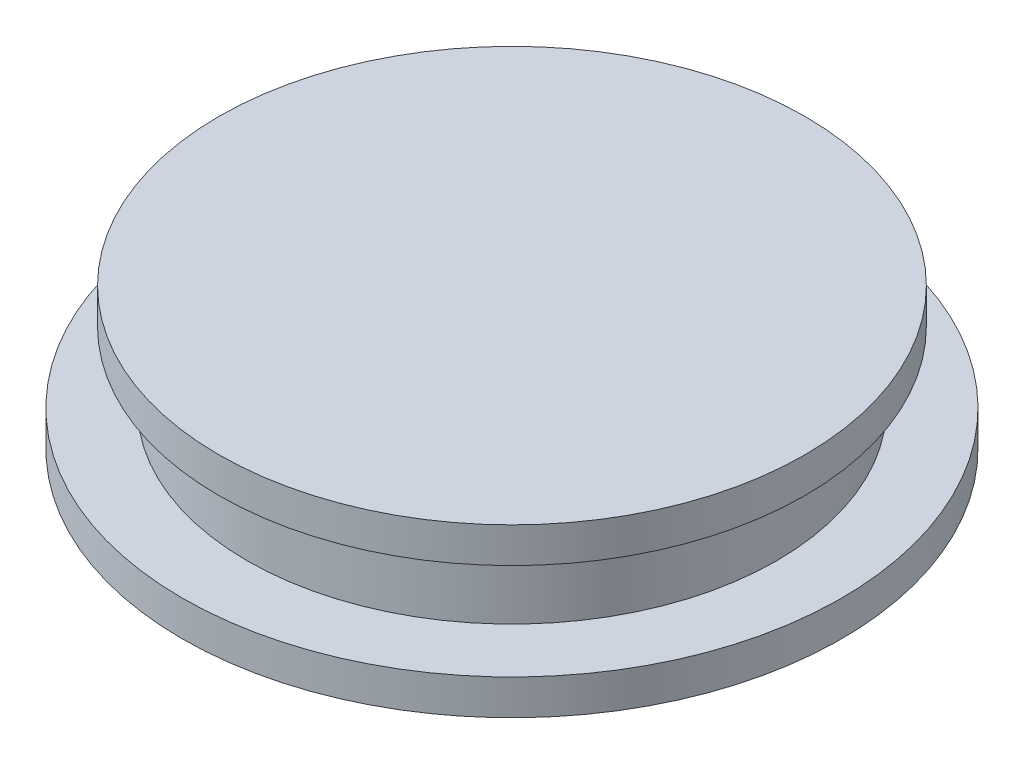
from build123d import *

# Parameters (mm, degrees)
SKETCH1_R           = 18.669
BOSS_EXTRUDE1_DEPTH = 2
SKETCH2_R           = 15
BOSS_EXTRUDE2_DEPTH = 4
SKETCH3_R           = 16.6
BOSS_EXTRUDE3_DEPTH = 2
SKETCH4_W           = 13.081
SKETCH4_H           = 13.081
CUT_EXTRUDE1_DEPTH  = 7
SKETCH5_W           = 13.081
SKETCH5_H           = 13.081
SKETCH5_W_2         = 10.922
SKETCH5_H_2         = 10.922
BOSS_EXTRUDE4_DEPTH = 1


with BuildPart() as part:
    # Sketch1 → Boss-Extrude1 (new body)
    with BuildSketch(Plane(origin=(0, 0, 0), x_dir=(1, 0, 0), z_dir=(0, 1, 0))):
        Circle(SKETCH1_R)
    extrude(amount=BOSS_EXTRUDE1_DEPTH)

    # Sketch2 → Boss-Extrude2 (add)
    with BuildSketch(Plane(origin=(0, 2, 0), x_dir=(1, 0, 0), z_dir=(0, 1, 0))):
        Circle(SKETCH2_R)
    extrude(amount=BOSS_EXTRUDE2_DEPTH)

    # Sketch3 → Boss-Extrude3 (add)
    with BuildSketch(Plane(origin=(0, 6, 0), x_dir=(1, 0, 0), z_dir=(0, 1, 0))):
        Circle(SKETCH3_R)
    extrude(amount=BOSS_EXTRUDE3_DEPTH)

    # Sketch4 → Cut-Extrude1 (cut)
    with BuildSketch(Plane(origin=(0, 0, 0), x_dir=(-1, 0, 0), z_dir=(0, -1, 0))):
        Rectangle(SKETCH4_W, SKETCH4_H)
    extrude(amount=-CUT_EXTRUDE1_DEPTH, mode=Mode.SUBTRACT)

    # Sketch5 → Boss-Extrude4 (add)
    with BuildSketch(Plane.XZ):
        Rectangle(SKETCH5_W, SKETCH5_H)
        Rectangle(SKETCH5_W_2, SKETCH5_H_2, mode=Mode.SUBTRACT)
    extrude(amount=-BOSS_EXTRUDE4_DEPTH)


solid = part.part
